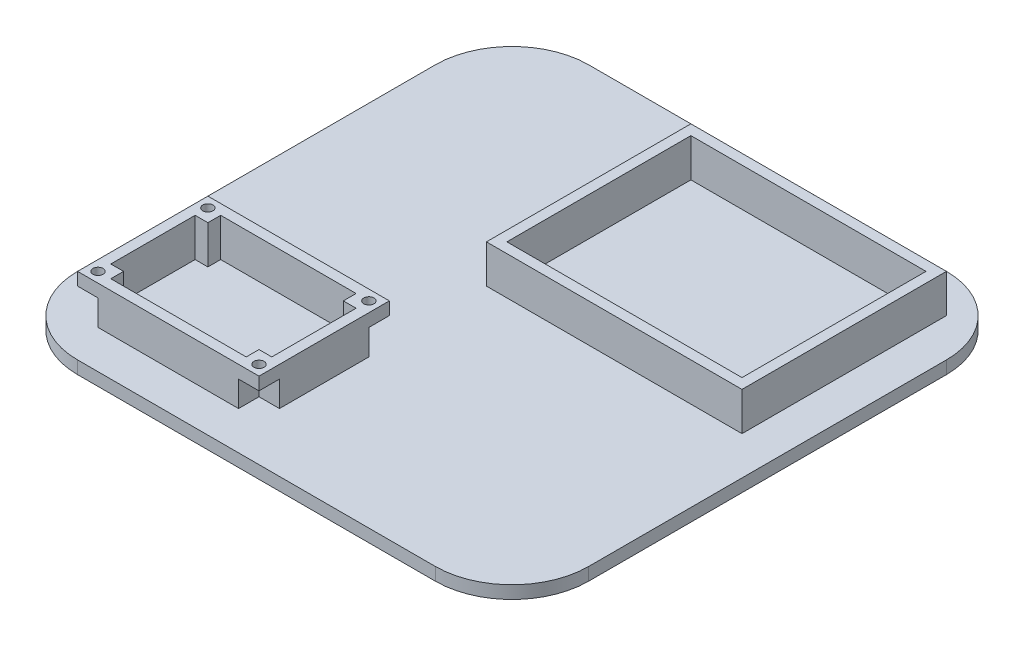
from build123d import *

# Parameters (mm, degrees)
SKETCH1_W            = 200
SKETCH1_H            = 200
BOSS_EXTRUDE1_DEPTH  = 5
SKETCH4_W            = 100
SKETCH4_H            = 80
SKETCH4_W_2          = 92
SKETCH4_H_2          = 72
BOSS_EXTRUDE2_DEPTH  = 15
SKETCH8_W            = 71
SKETCH8_H            = 51
SKETCH8_R            = 2
BOSS_EXTRUDE4_DEPTH  = 15
SKETCH9_W            = 8
SKETCH9_H            = 8
CUT_EXTRUDE11_DEPTH  = 10
LPATTERN1_COUNT      = 2
LPATTERN1_PITCH      = 63
LPATTERN1_COUNT_DIR2 = 2
LPATTERN1_PITCH_DIR2 = 43
FILLET1_R            = 30


with BuildPart() as part:
    # Sketch1 → Boss-Extrude1 (new body)
    with BuildSketch(Plane(origin=(0, 0, 0), x_dir=(1, 0, 0), z_dir=(0, 1, 0))):
        with Locations((100, 100)):
            Rectangle(SKETCH1_W, SKETCH1_H)
    extrude(amount=BOSS_EXTRUDE1_DEPTH)

    # Sketch4 → Boss-Extrude2 (add)
    with BuildSketch(Plane(origin=(0, 5, 0), x_dir=(1, 0, 0), z_dir=(0, 1, 0))):
        with Locations((135, 145)):
            Rectangle(SKETCH4_W, SKETCH4_H)
        with Locations((135, 145)):
            Rectangle(SKETCH4_W_2, SKETCH4_H_2, mode=Mode.SUBTRACT)
    extrude(amount=BOSS_EXTRUDE2_DEPTH)

    # Sketch8 → Boss-Extrude4 (add)
    with BuildSketch(Plane(origin=(0, 5, 0), x_dir=(1, 0, 0), z_dir=(0, 1, 0))):
        with Locations((50.5, 40.5)):
            Rectangle(SKETCH8_W, SKETCH8_H)
        with Locations((19, 62)):
            Circle(SKETCH8_R, mode=Mode.SUBTRACT)
        with Locations((82, 62)):
            Circle(SKETCH8_R, mode=Mode.SUBTRACT)
        with Locations((82, 19)):
            Circle(SKETCH8_R, mode=Mode.SUBTRACT)
        with Locations((19, 19)):
            Circle(SKETCH8_R, mode=Mode.SUBTRACT)
        Polygon((19, 57), (24, 57), (24, 62), (77, 62), (77, 57), (82, 57), (82, 24), (77, 24), (77, 19), (24, 19), (24, 24), (19, 24), align=None, mode=Mode.SUBTRACT)
    extrude(amount=BOSS_EXTRUDE4_DEPTH)

    # Sketch9 → Cut-Extrude11 (cut)
    with BuildSketch(Plane(origin=(0, 5, 0), x_dir=(1, 0, 0), z_dir=(0, 1, 0))):
        with Locations((19, 62)):
            Rectangle(SKETCH9_W, SKETCH9_H)
    cut_extrude11 = extrude(amount=CUT_EXTRUDE11_DEPTH, mode=Mode.SUBTRACT)

    # LPattern1: Cut-Extrude11 2 × 2
    with Locations(*[(i * LPATTERN1_PITCH, 0, j * LPATTERN1_PITCH_DIR2) for i in range(LPATTERN1_COUNT) for j in range(LPATTERN1_COUNT_DIR2) if (i, j) != (0, 0)]):
        add(cut_extrude11, mode=Mode.SUBTRACT)

    # Fillet1
    fillet1_edges = [part.edges().sort_by_distance(p)[0] for p in [
        (0, 2.5, -200),
        (200, 2.5, -200),
        (200, 2.5, 0),
        (0, 2.5, 0),
    ]]
    fillet(fillet1_edges, radius=FILLET1_R)


solid = part.part
